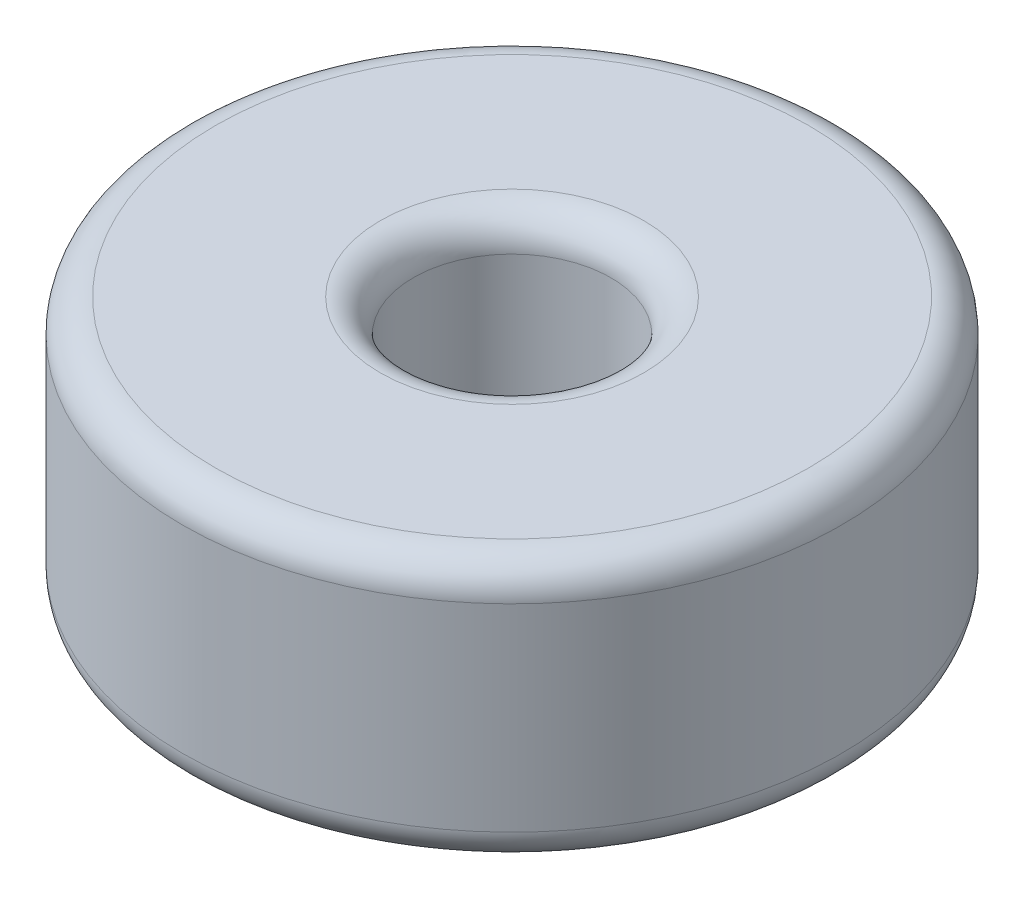
from build123d import *

# Parameters (mm, degrees)
SKETCH1_R           = 5
SKETCH1_R_2         = 1.5
BOSS_EXTRUDE1_DEPTH = 4
FILLET1_R           = 0.5


with BuildPart() as part:
    # Sketch1 → Boss-Extrude1 (new body)
    with BuildSketch(Plane(origin=(0, 0, 0), x_dir=(1, 0, 0), z_dir=(0, 1, 0))):
        Circle(SKETCH1_R)
        Circle(SKETCH1_R_2, mode=Mode.SUBTRACT)
    extrude(amount=BOSS_EXTRUDE1_DEPTH)

    # Fillet1
    fillet1_edges = [part.edges().sort_by_distance(p)[0] for p in [
        (-5, 0, 0),
        (-5, 4, 0),
        (-1.5, 0, 0),
        (-1.5, 4, 0),
    ]]
    fillet(fillet1_edges, radius=FILLET1_R)


solid = part.part
